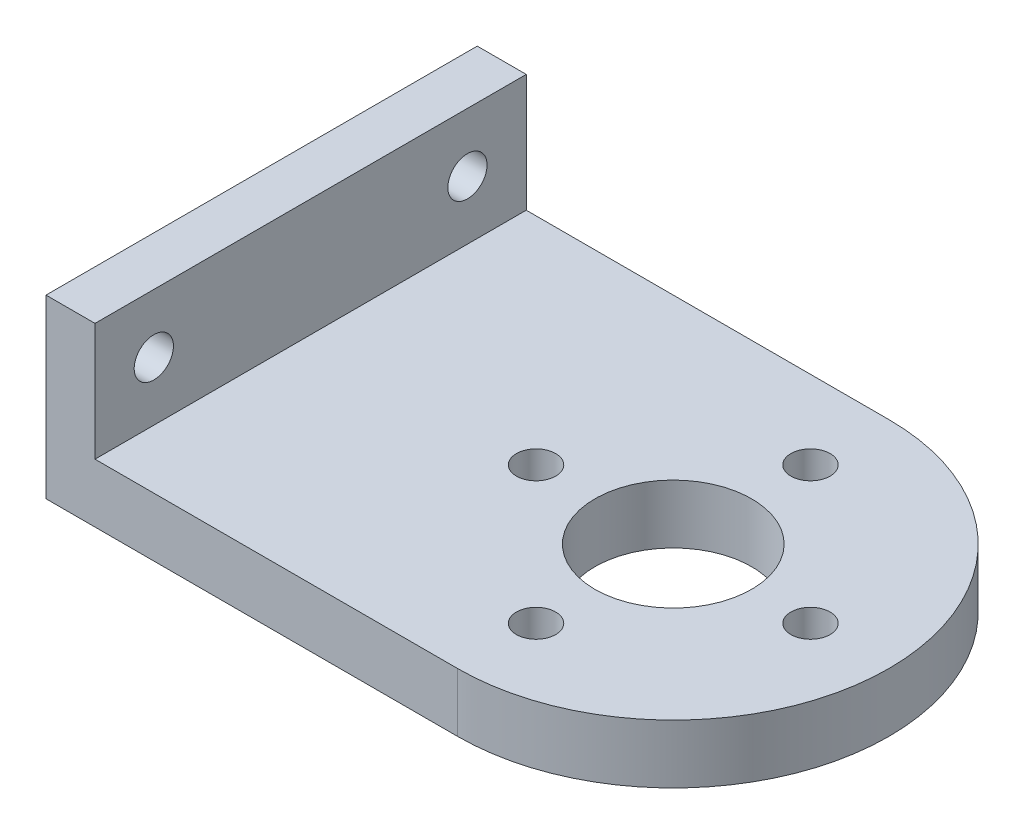
from build123d import *

# Parameters (mm, degrees)
SKETCH1_R           = 1
SKETCH1_R_2         = 4
BOSS_EXTRUDE1_DEPTH = 3
SKETCH2_W           = 2.5
SKETCH2_H           = 22
BOSS_EXTRUDE2_DEPTH = 6
SKETCH3_R           = 1
CUT_EXTRUDE1_DEPTH  = 6


with BuildPart() as part:
    # Sketch1 → Boss-Extrude1 (new body)
    with BuildSketch(Plane(origin=(0, 0, 0), x_dir=(1, 0, 0), z_dir=(0, 1, 0))):
        with BuildLine():
            Line((-14, -11), (-14, 11))
            Line((-14, 11), (7, 11))
            ThreePointArc((7, 11), (18, 0), (7, -11))
            Line((7, -11), (-14, -11))
        make_face()
        with Locations((7, -7)):
            Circle(SKETCH1_R, mode=Mode.SUBTRACT)
        Circle(SKETCH1_R, mode=Mode.SUBTRACT)
        with Locations((7, 0)):
            Circle(SKETCH1_R_2, mode=Mode.SUBTRACT)
        with Locations((14, 0)):
            Circle(SKETCH1_R, mode=Mode.SUBTRACT)
        with Locations((7, 7)):
            Circle(SKETCH1_R, mode=Mode.SUBTRACT)
    extrude(amount=BOSS_EXTRUDE1_DEPTH)

    # Sketch2 → Boss-Extrude2 (add)
    with BuildSketch(Plane(origin=(0, 3, 0), x_dir=(1, 0, 0), z_dir=(0, 1, 0))):
        with Locations((-12.75, 0)):
            Rectangle(SKETCH2_W, SKETCH2_H)
    extrude(amount=BOSS_EXTRUDE2_DEPTH)

    # Sketch3 → Cut-Extrude1 (cut)
    with BuildSketch(Plane(origin=(-11.5, 0, 0), x_dir=(0, 0, -1), z_dir=(1, 0, 0))):
        with Locations((8, 6)):
            Circle(SKETCH3_R)
        with Locations((-8, 6)):
            Circle(SKETCH3_R)
    extrude(amount=-CUT_EXTRUDE1_DEPTH, mode=Mode.SUBTRACT)


solid = part.part
